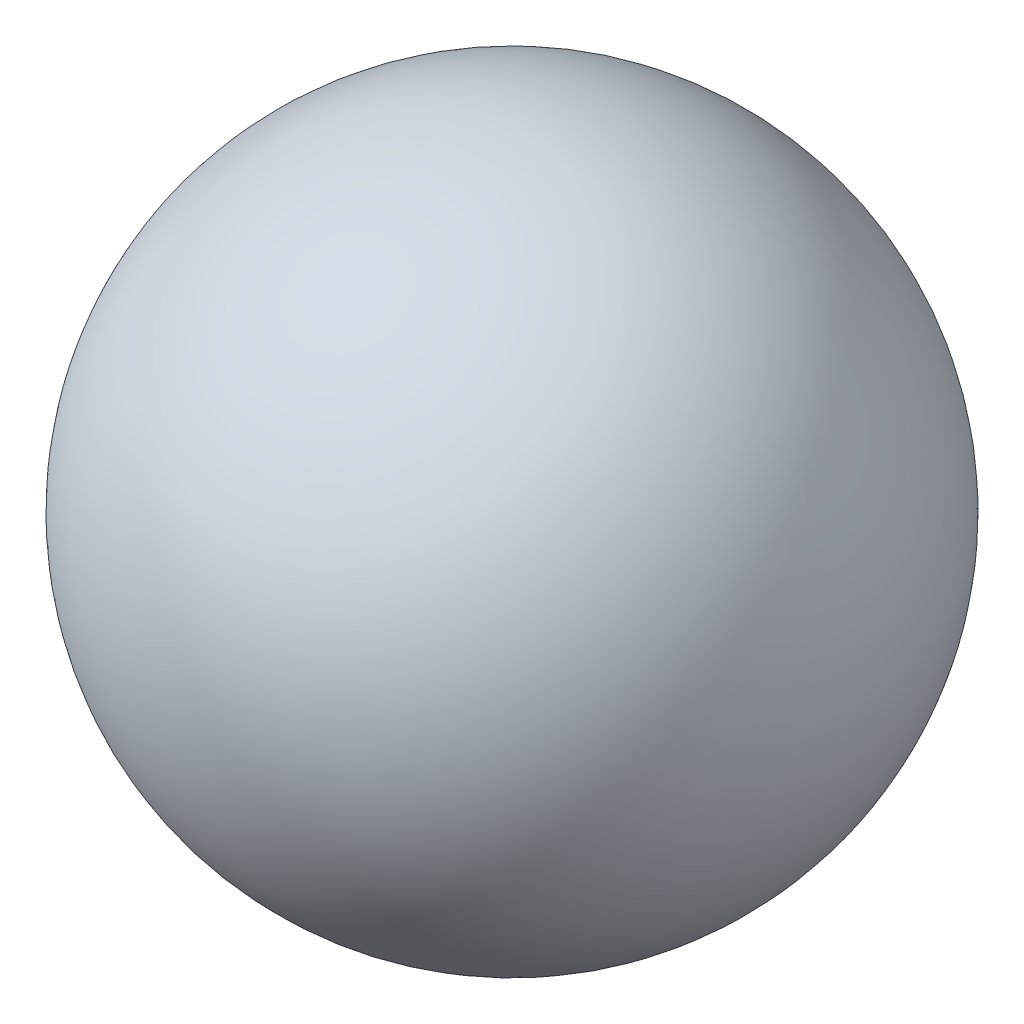
from build123d import *


with BuildPart() as part:
    # Sketch2 → Revolve5 (revolve)
    with BuildSketch(Plane(origin=(0, 0, 0), x_dir=(1, 0, 0), z_dir=(0, 1, 0))):
        with BuildLine():
            Line((-2.38125, 0), (2.38125, 0))
            ThreePointArc((2.38125, 0), (0, 2.38125), (-2.38125, 0))
        make_face()
    revolve(axis=Axis((-1.868845666, 0, 0), (1, 0, 0)))


solid = part.part
